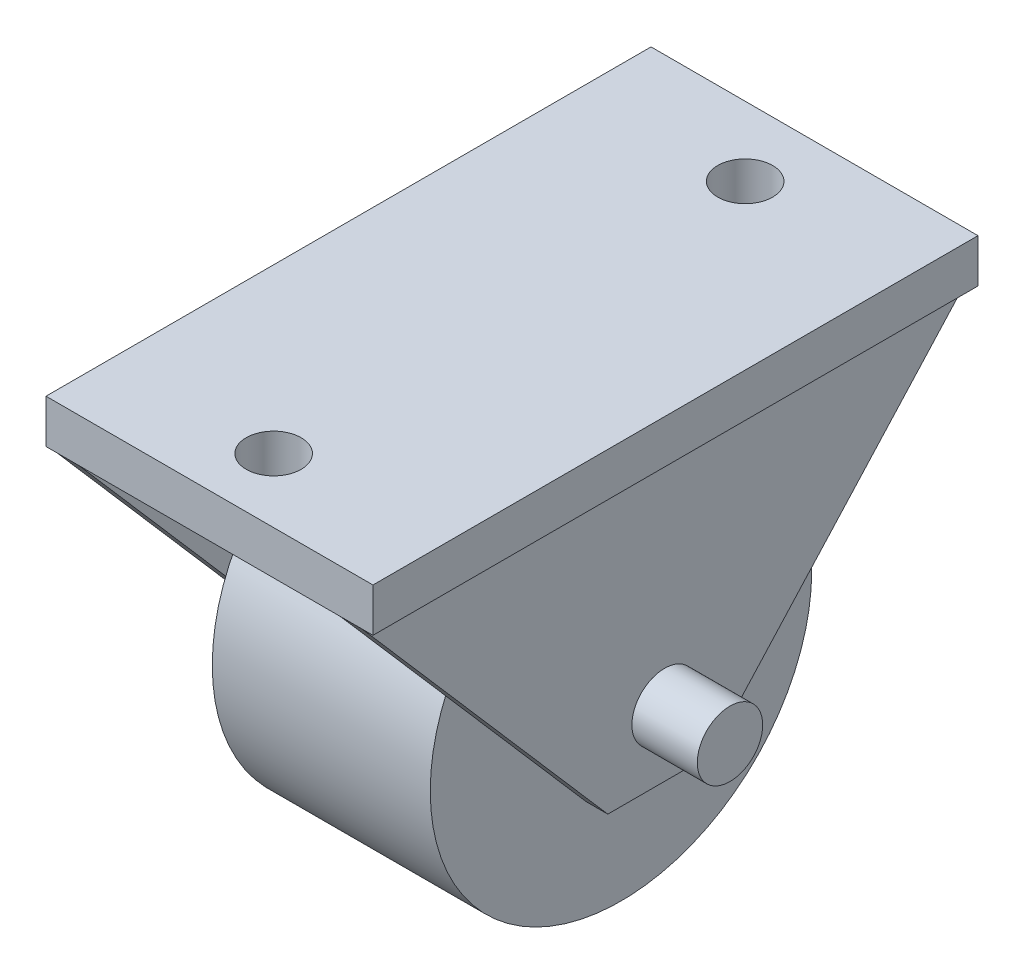
from build123d import *

# Parameters (mm, degrees)
SKETCH1_R           = 8.75
SKETCH1_R_2         = 1.5
BOSS_EXTRUDE1_DEPTH = 5
SKETCH1_2_R         = 1.5
BOSS_EXTRUDE2_DEPTH = 10
BOSS_EXTRUDE3_START = 10
SKETCH2_W           = 15
SKETCH2_H           = 27.755893748
SKETCH2_R           = 1.259283935
BOSS_EXTRUDE3_DEPTH = 2
BOSS_EXTRUDE4_START = 6
BOSS_EXTRUDE4_DEPTH = 1
BOSS_EXTRUDE5_START = -6
BOSS_EXTRUDE5_DEPTH = 1


with BuildPart() as part:
    # Sketch1 → Boss-Extrude1 (new, symmetric)
    with BuildSketch(Plane(origin=(0, 0, 0), x_dir=(0, 0, -1), z_dir=(1, 0, 0))):
        Circle(SKETCH1_R)
        Circle(SKETCH1_R_2, mode=Mode.SUBTRACT)
    extrude(amount=BOSS_EXTRUDE1_DEPTH, both=True)

    # Sketch1_2 → Boss-Extrude2 (add, symmetric)
    with BuildSketch(Plane(origin=(0, 0, 0), x_dir=(0, 0, -1), z_dir=(1, 0, 0))):
        Circle(SKETCH1_2_R)
    extrude(amount=BOSS_EXTRUDE2_DEPTH, both=True)



with BuildPart() as body_2:
    # Sketch2 → Boss-Extrude3 (new body)
    with BuildSketch(Plane(origin=(0, 0, 0), x_dir=(1, 0, 0), z_dir=(0, 1, 0)).offset(BOSS_EXTRUDE3_START)):
        Rectangle(SKETCH2_W, SKETCH2_H)
        with Locations((0, 10.696409263)):
            Circle(SKETCH2_R, mode=Mode.SUBTRACT)
        with Locations((0, -10.934061862)):
            Circle(SKETCH2_R, mode=Mode.SUBTRACT)
    extrude(amount=BOSS_EXTRUDE3_DEPTH)


with BuildPart() as part_1:
    add(part.part)

    add(body_2.part)  # Boss-Extrude4 merges body 2
    # Sketch3 → Boss-Extrude4 (add)
    with BuildSketch(Plane(origin=(0, 0, 0), x_dir=(0, 0, -1), z_dir=(1, 0, 0)).offset(BOSS_EXTRUDE4_START)):
        Polygon((-13.877946874, 10), (-2.605119046, -2.991355361), (2.097655879, -2.991355361), (13.877946874, 10), align=None)
    extrude(amount=BOSS_EXTRUDE4_DEPTH)

    # Sketch3_2 → Boss-Extrude5 (add)
    with BuildSketch(Plane(origin=(0, 0, 0), x_dir=(0, 0, -1), z_dir=(1, 0, 0)).offset(BOSS_EXTRUDE5_START)):
        Polygon((-13.877946874, 10), (-2.605119046, -2.991355361), (2.097655879, -2.991355361), (13.877946874, 10), align=None)
    extrude(amount=-BOSS_EXTRUDE5_DEPTH)


solid = part_1.part
